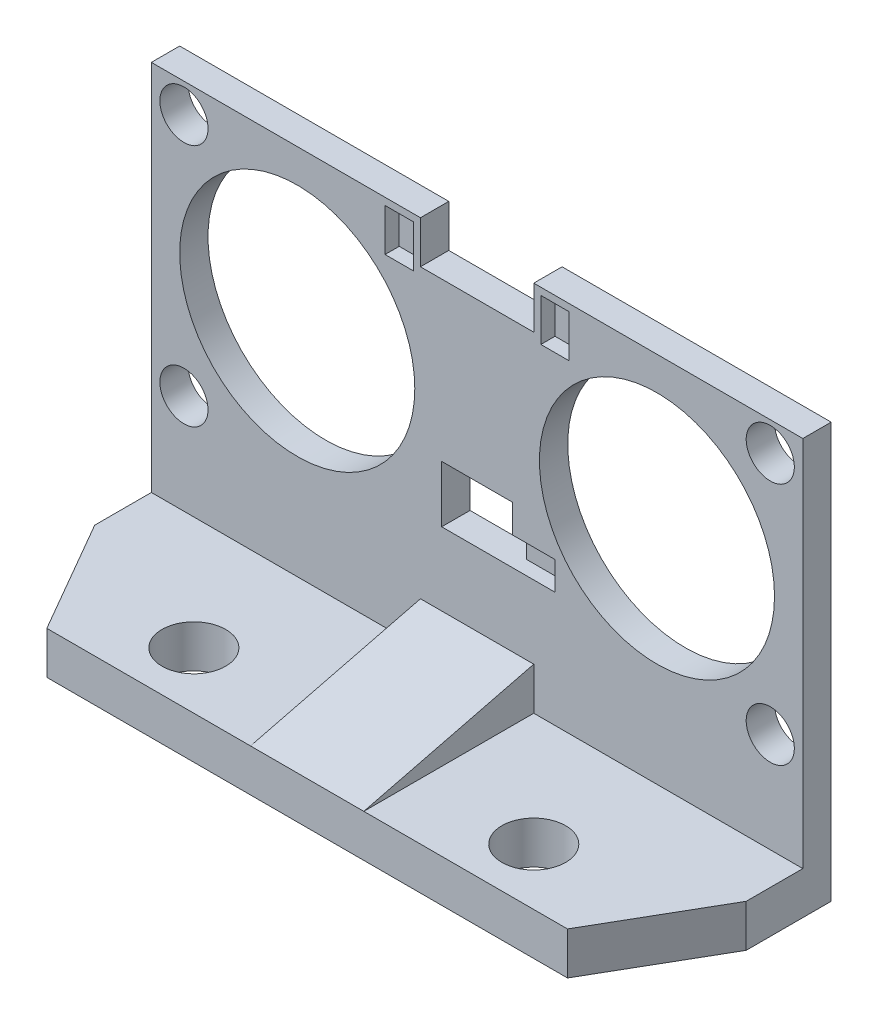
from build123d import *
from OCP.BRepFilletAPI import BRepFilletAPI_MakeChamfer

# Parameters (mm, degrees)
SKETCH_1_W          = 46
SKETCH_1_H          = 21.3
EXTRUDE_1_DEPTH     = 2
SKETCH_2_R          = 8.3
CUT_EXTRUDE_1_DEPTH = 26.424840216
SKETCH_3_W          = 8
SKETCH_3_H          = 3
CUT_EXTRUDE_2_DEPTH = 26.424840216
SKETCH_4_W          = 5
SKETCH_4_H          = 4
CUT_EXTRUDE_3_DEPTH = 26.424840216
SKETCH_5_W          = 3
SKETCH_5_H          = 2
SKETCH_5_W_2        = 2
SKETCH_5_H_2        = 3
CUT_EXTRUDE_4_DEPTH = 1
SKETCH_8_W          = 46
SKETCH_8_H          = 2
EXTRUDE_2_DEPTH     = 5
SKETCH_9_W          = 46
SKETCH_9_H          = 14
EXTRUDE_3_DEPTH     = 3
HOLE_WIZARD_M3_1_D  = 3.4
HOLE_WIZARD_M4_1_D  = 4.5
RIB_1_REACH         = 34.754
SKETCH_13_WALL_W    = 79.877255328
SKETCH_13_WALL_H    = 8
CHAMFER_1_SIZE      = 8
CHAMFER_1_SIZE2     = 4.618802154


with BuildPart() as part:
    # 草圖1 → 填料-伸長1 (new body)
    with BuildSketch(Plane.XY):
        Rectangle(SKETCH_1_W, SKETCH_1_H)
    extrude(amount=EXTRUDE_1_DEPTH)

    # 草圖2 → 除料-伸長1 (cut, through all)
    with BuildSketch(Plane.XY.offset(2)):
        with Locations((-12.7, 0)):
            Circle(SKETCH_2_R)
        with Locations((12.7, 0)):
            Circle(SKETCH_2_R)
    extrude(amount=-CUT_EXTRUDE_1_DEPTH, mode=Mode.SUBTRACT)

    # 草圖3 → 除料-伸長2 (cut, through all)
    with BuildSketch(Plane.XY.offset(2)):
        with Locations((0, 9.15)):
            Rectangle(SKETCH_3_W, SKETCH_3_H)
    extrude(amount=-CUT_EXTRUDE_2_DEPTH, mode=Mode.SUBTRACT)

    # 草圖4 → 除料-伸長3 (cut, through all)
    with BuildSketch(Plane.XY.offset(2)):
        with Locations((0, -5.5)):
            Rectangle(SKETCH_4_W, SKETCH_4_H)
    extrude(amount=-CUT_EXTRUDE_3_DEPTH, mode=Mode.SUBTRACT)

    # 草圖5 → 除料-伸長4 (cut)
    with BuildSketch(Plane.XY.offset(2)):
        with Locations((4, -6.5)):
            Rectangle(SKETCH_5_W, SKETCH_5_H)
        with Locations((-5.5, 8.65)):
            Rectangle(SKETCH_5_W_2, SKETCH_5_H_2)
        with Locations((5.5, 8.65)):
            Rectangle(SKETCH_5_W_2, SKETCH_5_H_2)
    extrude(amount=-CUT_EXTRUDE_4_DEPTH, mode=Mode.SUBTRACT)

    # 草圖8 → 填料-伸長2 (add)
    with BuildSketch(Plane.XZ.offset(10.65)):
        with Locations((0, 1)):
            Rectangle(SKETCH_8_W, SKETCH_8_H)
    extrude(amount=EXTRUDE_2_DEPTH)

    # 草圖9 → 填料-伸長3 (add)
    with BuildSketch(Plane.XZ.offset(15.65)):
        with Locations((0, 7)):
            Rectangle(SKETCH_9_W, SKETCH_9_H)
    extrude(amount=EXTRUDE_3_DEPTH)

    # M3 餘隙孔1 (through all)
    with Locations(Plane.XY.offset(2)):
        with Locations((20.7, 8.6), (-20.7, -8.6), (-20.7, 8.6), (20.7, -8.6)):
            Hole(HOLE_WIZARD_M3_1_D / 2)

    # M4 餘隙孔1 (through all)
    with Locations(Plane(origin=(0, -15.65, 0), x_dir=(1, 0, 0), z_dir=(0, 1, 0))):
        with Locations((12, -10), (-12, -10)):
            Hole(HOLE_WIZARD_M4_1_D / 2)

    # 草圖13 wall → 肋材1 (add, up to next)
    with BuildSketch(Plane(origin=(0, -14.15, 8), x_dir=(0, -0.242535625036, 0.970142500145), z_dir=(0, -0.970142500145, -0.242535625036)), mode=Mode.PRIVATE) as rib_1_sk1:
        Rectangle(SKETCH_13_WALL_W, SKETCH_13_WALL_H)
    rib_1_tool1 = extrude(rib_1_sk1.sketch, amount=RIB_1_REACH, mode=Mode.PRIVATE) - part.part
    add(rib_1_tool1.solids().sort_by_distance((0, -14.15, 8))[0])

    # 導角1: one chamfer whose edges measure the first distance from different faces: ONE call of the kernel's chamfer builder (chamfer() names one face for all edges)
    chamfer_1_edges_1 = [part.edges().sort_by_distance(p)[0] for p in [
        (-23, -17.15, 14),
    ]]
    chamfer_1_side_1 = [part.faces().sort_by_distance(p)[0] for p in [
        (-23, 10.325270882, 1),
    ]]
    chamfer_1_edges_2 = [part.edges().sort_by_distance(p)[0] for p in [
        (23, -17.15, 14),
    ]]
    chamfer_1_side_2 = [part.faces().sort_by_distance(p)[0] for p in [
        (23, 10.325270882, 1),
    ]]
    chamfer_1 = BRepFilletAPI_MakeChamfer(part.part.solid().wrapped)
    for e in chamfer_1_edges_1:
        chamfer_1.Add(CHAMFER_1_SIZE, CHAMFER_1_SIZE2, e.wrapped, chamfer_1_side_1[0].wrapped)  # the first distance lies on this face
    for e in chamfer_1_edges_2:
        chamfer_1.Add(CHAMFER_1_SIZE, CHAMFER_1_SIZE2, e.wrapped, chamfer_1_side_2[0].wrapped)  # the first distance lies on this face
    add(Compound.cast(chamfer_1.Shape()), mode=Mode.REPLACE)


solid = part.part
